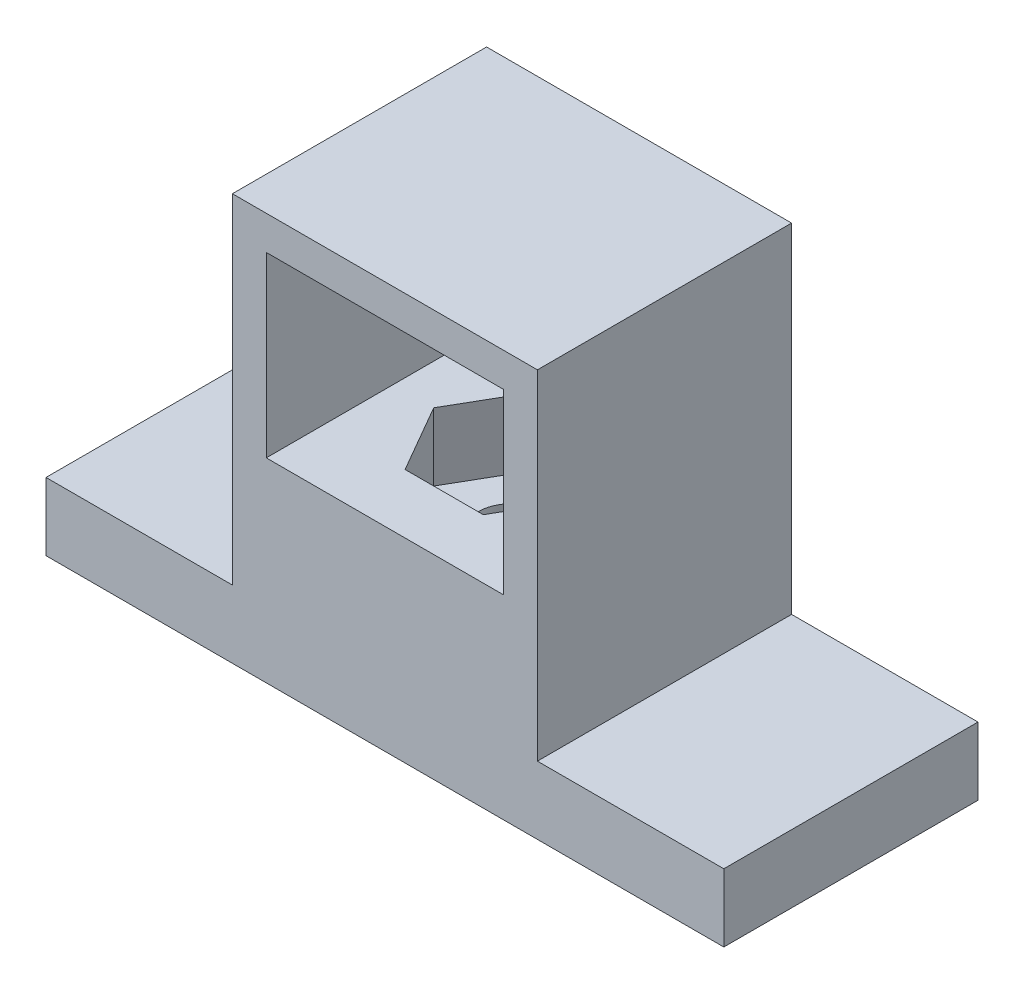
from build123d import *

# Parameters (mm, degrees)
BASESKETCH_W       = 40
BASESKETCH_H       = 15
BASE_DEPTH         = 4
HOLDERSKETCH_W     = 18
HOLDERSKETCH_H     = 15
HOLDER_DEPTH       = 20
MOTORCUTSKETCH_W   = 14
MOTORCUTSKETCH_H   = 10.5
MOTORCUT_DEPTH     = 19
NUTTHOLE_DEPTH     = 4
HOLESKETCH_R       = 2
CUT_EXTRUDE3_DEPTH = 64


with BuildPart() as part:
    # BaseSketch → Base (new body)
    with BuildSketch(Plane(origin=(0, 0, 0), x_dir=(1, 0, 0), z_dir=(0, 1, 0))):
        Rectangle(BASESKETCH_W, BASESKETCH_H)
    extrude(amount=BASE_DEPTH)

    # HolderSketch → Holder (add)
    with BuildSketch(Plane(origin=(0, 4, 0), x_dir=(1, 0, 0), z_dir=(0, 1, 0))):
        Rectangle(HOLDERSKETCH_W, HOLDERSKETCH_H)
    extrude(amount=HOLDER_DEPTH)

    # MotorCutSketch → MotorCut (cut)
    with BuildSketch(Plane.XY.offset(7.5)):
        with Locations((0, 16.75)):
            Rectangle(MOTORCUTSKETCH_W, MOTORCUTSKETCH_H)
    extrude(amount=-MOTORCUT_DEPTH, mode=Mode.SUBTRACT)

    # NuttHoleSketch → NuttHole (cut)
    with BuildSketch(Plane(origin=(0, 11.5, 0), x_dir=(1, 0, 0), z_dir=(0, 1, 0))):
        Polygon((-2.309401077, 4), (-4.618802154, 0), (-2.309401077, -4), (2.309401077, -4), (4.618802154, 0), (2.309401077, 4), align=None)
    extrude(amount=-NUTTHOLE_DEPTH, mode=Mode.SUBTRACT)

    # HoleSketch → Cut-Extrude3 (cut)
    with BuildSketch(Plane(origin=(0, 7.5, 0), x_dir=(1, 0, 0), z_dir=(0, 1, 0))):
        Circle(HOLESKETCH_R)
    extrude(amount=-CUT_EXTRUDE3_DEPTH, mode=Mode.SUBTRACT)


solid = part.part
